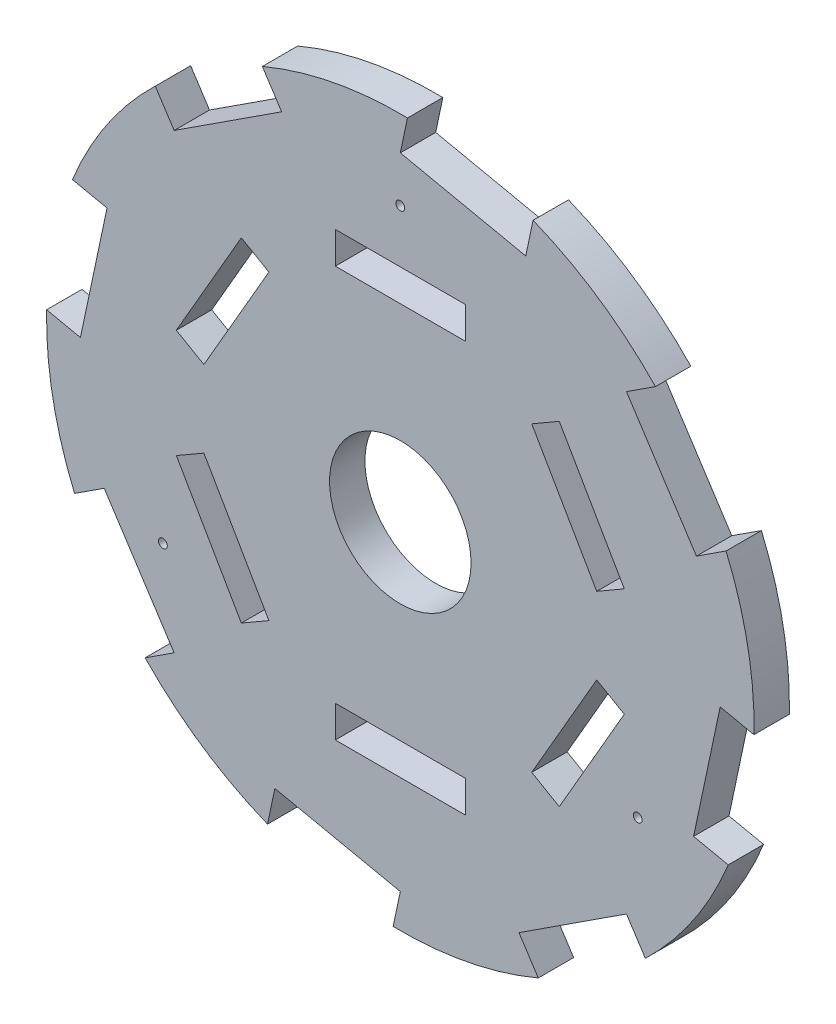
from build123d import *

# Parameters (mm, degrees)
AUFSATZ_LINEAR_AUSTRAGEN1_DEPTH = 4
SCHNITT_LINEAR_AUSTRAGEN1_REACH = 6
SKIZZE2_R                       = 8
SKIZZE4_W                       = 14.7
SKIZZE4_H                       = 3.6
SCHNITT_LINEAR_AUSTRAGEN2_DEPTH = 4
KREISMUSTER1_COUNT              = 6
SKIZZE5_R                       = 0.5
SCHNITT_LINEAR_AUSTRAGEN3_DEPTH = 4
KREISMUSTER2_COUNT              = 3


with BuildPart() as part:
    # Skizze1 → Aufsatz-Linear austragen1 (new body)
    with BuildSketch(Plane.XY):
        with BuildLine():
            Line((0, 36.168934028), (14.18455057, 33.162270875))
            Line((14.18455057, 33.162270875), (15.013991658, 37.075329459))
            ThreePointArc((15.013991658, 37.075329459), (22.427500118, 33.121099596), (28.851450623, 27.705483157))
            Line((28.851450623, 27.705483157), (25.57529852, 25.57529852))
            Line((25.57529852, 25.57529852), (33.479258511, 13.41927472))
            Line((33.479258511, 13.41927472), (36.832712189, 15.599721561))
            ThreePointArc((36.832712189, 15.599721561), (39.278791543, 7.561516706), (39.991791399, -0.810321366))
            Line((39.991791399, -0.810321366), (36.168934028, 0))
            Line((36.168934028, 0), (33.162270875, -14.18455057))
            Line((33.162270875, -14.18455057), (37.075329459, -15.013991658))
            ThreePointArc((37.075329459, -15.013991658), (33.121099596, -22.427500118), (27.705483157, -28.851450623))
            Line((27.705483157, -28.851450623), (25.57529852, -25.57529852))
            Line((25.57529852, -25.57529852), (13.41927472, -33.479258511))
            Line((13.41927472, -33.479258511), (15.599721561, -36.832712189))
            ThreePointArc((15.599721561, -36.832712189), (7.561516706, -39.278791543), (-0.810321366, -39.991791399))
            Line((-0.810321366, -39.991791399), (0, -36.168934028))
            Line((0, -36.168934028), (-14.18455057, -33.162270875))
            Line((-14.18455057, -33.162270875), (-15.013991658, -37.075329459))
            ThreePointArc((-15.013991658, -37.075329459), (-22.427500118, -33.121099596), (-28.851450623, -27.705483157))
            Line((-28.851450623, -27.705483157), (-25.57529852, -25.57529852))
            Line((-25.57529852, -25.57529852), (-33.479258511, -13.41927472))
            Line((-33.479258511, -13.41927472), (-36.832712189, -15.599721561))
            ThreePointArc((-36.832712189, -15.599721561), (-39.278791543, -7.561516706), (-39.991791399, 0.810321366))
            Line((-39.991791399, 0.810321366), (-36.168934028, 0))
            Line((-36.168934028, 0), (-33.162270875, 14.18455057))
            Line((-33.162270875, 14.18455057), (-37.075329459, 15.013991658))
            ThreePointArc((-37.075329459, 15.013991658), (-33.121099596, 22.427500118), (-27.705483157, 28.851450623))
            Line((-27.705483157, 28.851450623), (-25.57529852, 25.57529852))
            Line((-25.57529852, 25.57529852), (-13.41927472, 33.479258511))
            Line((-13.41927472, 33.479258511), (-15.599721561, 36.832712189))
            ThreePointArc((-15.599721561, 36.832712189), (-7.561516706, 39.278791543), (0.810321366, 39.991791399))
            Line((0.810321366, 39.991791399), (0, 36.168934028))
        make_face()
    extrude(amount=AUFSATZ_LINEAR_AUSTRAGEN1_DEPTH)

    # Skizze2 → Schnitt-Linear austragen1 (cut, up to next)
    with BuildSketch(Plane.XY.offset(4), mode=Mode.PRIVATE) as schnitt_linear_austragen1_sk1:
        Circle(SKIZZE2_R)
    schnitt_linear_austragen1_tool1 = extrude(schnitt_linear_austragen1_sk1.sketch, amount=-SCHNITT_LINEAR_AUSTRAGEN1_REACH, mode=Mode.PRIVATE) & part.part
    add(schnitt_linear_austragen1_tool1.solids().sort_by_distance((0, 0, 4))[0], mode=Mode.SUBTRACT)

    # Skizze4 → Schnitt-Linear austragen2 (cut)
    with BuildSketch(Plane.XY.offset(4)):
        with Locations((0, 23.2)):
            Rectangle(SKIZZE4_W, SKIZZE4_H)
    schnitt_linear_austragen2 = extrude(amount=-SCHNITT_LINEAR_AUSTRAGEN2_DEPTH, mode=Mode.SUBTRACT)

    # Kreismuster1: Schnitt-Linear austragen2 ×6 about axis
    kreismuster1_axis = Axis((0, 0, 0), (0, 0, 1))
    for i in range(1, KREISMUSTER1_COUNT):
        add(schnitt_linear_austragen2.rotate(kreismuster1_axis, i * 360 / KREISMUSTER1_COUNT), mode=Mode.SUBTRACT)

    # Skizze5 → Schnitt-Linear austragen3 (cut)
    with BuildSketch(Plane.XY.offset(4)):
        with Locations((0, 31)):
            Circle(SKIZZE5_R)
    schnitt_linear_austragen3 = extrude(amount=-SCHNITT_LINEAR_AUSTRAGEN3_DEPTH, mode=Mode.SUBTRACT)

    # Kreismuster2: Schnitt-Linear austragen3 ×3 about axis
    kreismuster2_axis = Axis((0, 0, 0), (0, 0, 1))
    for i in range(1, KREISMUSTER2_COUNT):
        add(schnitt_linear_austragen3.rotate(kreismuster2_axis, i * 360 / KREISMUSTER2_COUNT), mode=Mode.SUBTRACT)


solid = part.part
